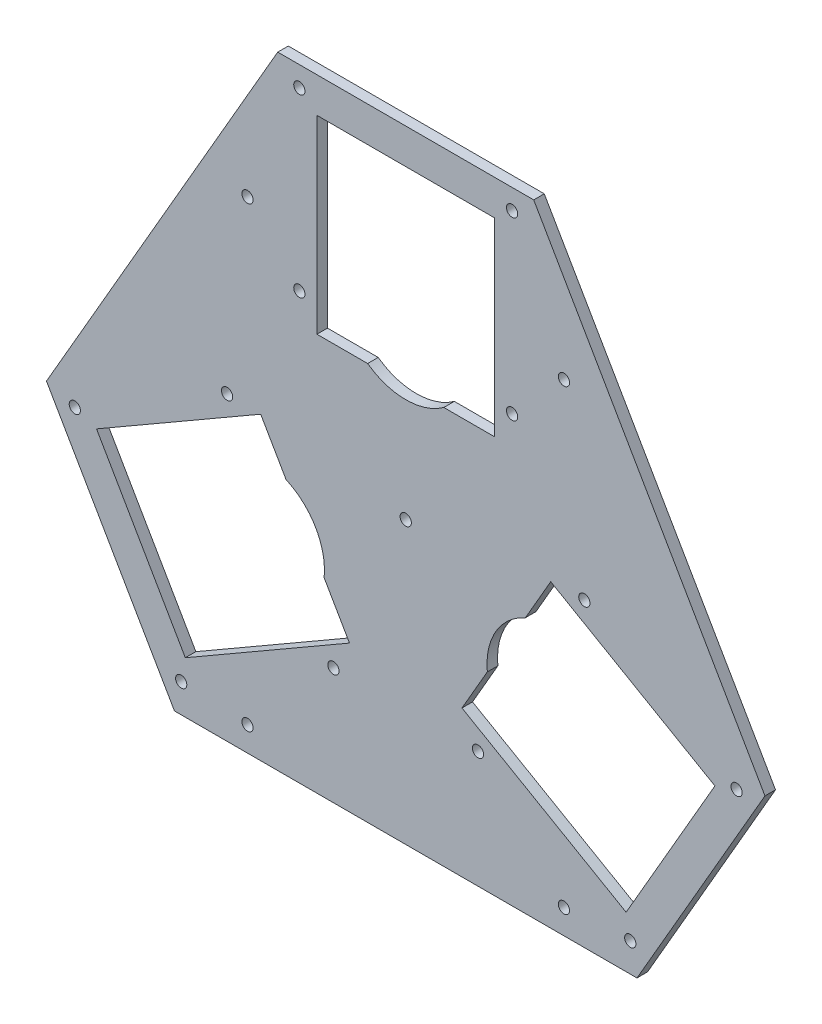
from build123d import *

# Parameters (mm, degrees)
SKETCH_1_R          = 1.6
SKETCH_1_W          = 50.5
SKETCH_1_H          = 53.910884284
EXTRUDE_1_DEPTH     = 3
CUT_EXTRUDE_1_DEPTH = 4


with BuildPart() as part:
    # ｽｹｯﾁ1 → ﾎﾞｽ - 押し出し1 (new body)
    with BuildSketch(Plane.XY):
        Polygon((-36.39879245, 96.955442142), (36.39879245, 96.955442142), (102.165272155, -16.955442142), (65.766479705, -80), (-65.766479705, -80), (-102.165272155, -16.955442142), align=None)
        with Locations((30.25, 91.195498156)):
            Circle(SKETCH_1_R, mode=Mode.SUBTRACT)
        with Locations((30.25, 41.195498156)):
            Circle(SKETCH_1_R, mode=Mode.SUBTRACT)
        with Locations((-30.25, 41.195498156)):
            Circle(SKETCH_1_R, mode=Mode.SUBTRACT)
        with Locations((-30.25, 91.195498156)):
            Circle(SKETCH_1_R, mode=Mode.SUBTRACT)
        with Locations((63.852618114, -71.795017542)):
            Circle(SKETCH_1_R, mode=Mode.SUBTRACT)
        with Locations((94.102618114, -19.400480613)):
            Circle(SKETCH_1_R, mode=Mode.SUBTRACT)
        with Locations((50.801347925, 5.599519387)):
            Circle(SKETCH_1_R, mode=Mode.SUBTRACT)
        with Locations((20.551347925, -46.795017542)):
            Circle(SKETCH_1_R, mode=Mode.SUBTRACT)
        with Locations((-94.102618114, -19.400480613)):
            Circle(SKETCH_1_R, mode=Mode.SUBTRACT)
        with Locations((-63.852618114, -71.795017542)):
            Circle(SKETCH_1_R, mode=Mode.SUBTRACT)
        with Locations((-20.551347925, -46.795017542)):
            Circle(SKETCH_1_R, mode=Mode.SUBTRACT)
        with Locations((-50.801347925, 5.599519387)):
            Circle(SKETCH_1_R, mode=Mode.SUBTRACT)
        with Locations((-45, 57)):
            Circle(SKETCH_1_R, mode=Mode.SUBTRACT)
        with Locations((45, 57)):
            Circle(SKETCH_1_R, mode=Mode.SUBTRACT)
        with Locations((45, -73)):
            Circle(SKETCH_1_R, mode=Mode.SUBTRACT)
        with Locations((-45, -73)):
            Circle(SKETCH_1_R, mode=Mode.SUBTRACT)
        Circle(SKETCH_1_R, mode=Mode.SUBTRACT)
        with Locations((0, 60)):
            Rectangle(SKETCH_1_W, SKETCH_1_H, mode=Mode.SUBTRACT)
        Polygon((87.930621892, -21.610579625), (62.680621892, -65.344862517), (15.992426562, -38.389420375), (41.242426562, 5.344862517), align=None, mode=Mode.SUBTRACT)
        Polygon((-62.680621892, -65.344862517), (-87.930621892, -21.610579625), (-41.242426562, 5.344862517), (-15.992426562, -38.389420375), align=None, mode=Mode.SUBTRACT)
    extrude(amount=EXTRUDE_1_DEPTH)

    # ｽｹｯﾁ2 → ｶｯﾄ - 押し出し1 (cut, through all)
    with BuildSketch(Plane.XY.offset(3)):
        with BuildLine():
            Line((-10.828203914, 33.044557858), (10.828203914, 33.044557858))
            ThreePointArc((10.828203914, 33.044557858), (0, 29.544557858), (-10.828203914, 33.044557858))
        make_face()
        with BuildLine():
            Line((34.031528519, -7.144779262), (23.203324605, -25.899778596))
            ThreePointArc((23.203324605, -25.899778596), (25.586337649, -14.772278929), (34.031528519, -7.144779262))
        make_face()
        with BuildLine():
            Line((-23.203324605, -25.899778596), (-34.031528519, -7.144779262))
            ThreePointArc((-34.031528519, -7.144779262), (-25.586337649, -14.772278929), (-23.203324605, -25.899778596))
        make_face()
    extrude(amount=-CUT_EXTRUDE_1_DEPTH, mode=Mode.SUBTRACT)


solid = part.part
